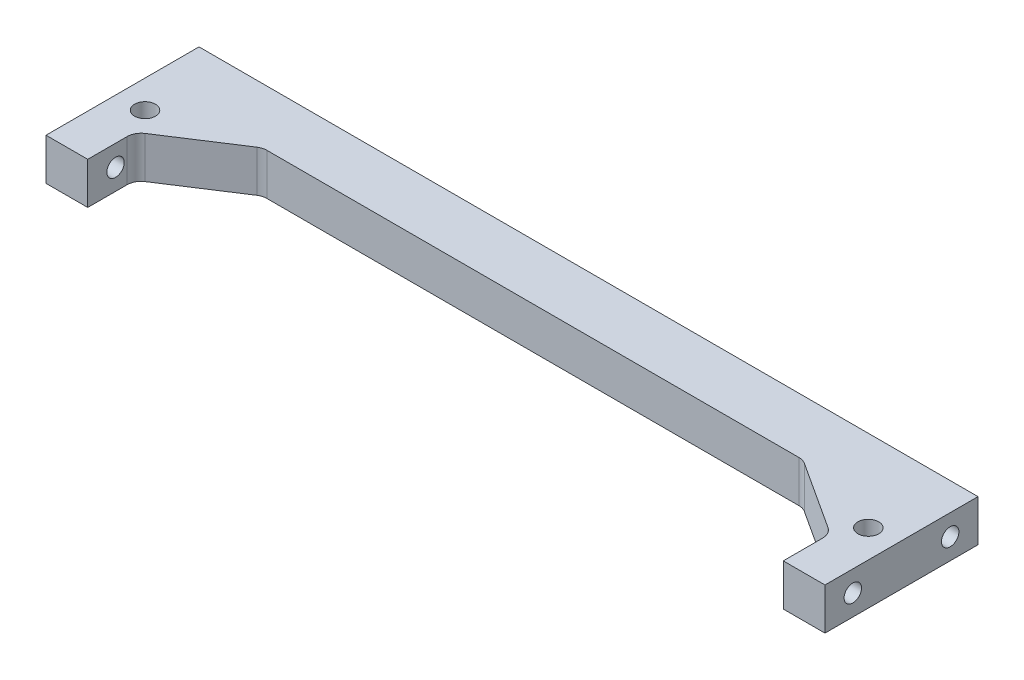
from build123d import *

# Parameters (mm, degrees)
SKETCH1_R                        = 1.5
BOSS_EXTRUDE1_DEPTH              = 6
FILLET1_R                        = 2
TAP_DRILL_FOR_M3_TAP1_AT_2_COUNT = 2
TAP_DRILL_FOR_M3_TAP1_AT_2_PITCH = 14
FILLET1_OF_MIRROR1_R             = 2


with BuildPart() as part:
    # Sketch1 → Boss-Extrude1 (new body)
    with BuildSketch(Plane(origin=(0, 0, 0), x_dir=(1, 0, 0), z_dir=(0, 1, 0))):
        Polygon((0, -22), (-56, -22), (-56, -44), (-50, -44), (-50, -37.239832831), (-38.851635079, -30), (0, -30), align=None)
        with Locations(Location((-51.997575213, -33.767620171, 0), (0, 0, 270))):
            Circle(SKETCH1_R, mode=Mode.SUBTRACT)
    boss_extrude1 = extrude(amount=BOSS_EXTRUDE1_DEPTH)

    # Fillet1
    fillet1_edges = [part.edges().sort_by_distance(p)[0] for p in [
        (-38.851635079, 3, 30),
        (-50, 3, 37.239832831),
    ]]
    fillet(fillet1_edges, radius=FILLET1_R)

    # Sketch2 → Tap Drill for M3 Tap1 (revolve, cut)
    with BuildSketch(Plane(origin=(-56, 3, 26), x_dir=(0, 0, 1), z_dir=(0, 1, 0))):
        Polygon((0, 0), (0, 10.751075774), (1.25, 10), (1.25, 0), align=None)
    tap_drill_for_m3_tap1 = revolve(axis=Axis((-62.35, 3, 26), (1, 0, 0)), mode=Mode.SUBTRACT)

    # Tap Drill for M3 Tap1 at 2: Tap Drill for M3 Tap1 ×2
    with Locations(*[(0, 0, i * TAP_DRILL_FOR_M3_TAP1_AT_2_PITCH) for i in range(1, TAP_DRILL_FOR_M3_TAP1_AT_2_COUNT)]):
        add(tap_drill_for_m3_tap1, mode=Mode.SUBTRACT)

    # Mirror1: Boss-Extrude1, Tap Drill for M3 Tap1 across plane
    add(boss_extrude1.mirror(Plane(origin=(0, 6, 30), x_dir=(0, 0, 1), z_dir=(-1, 0, 0))))
    add(tap_drill_for_m3_tap1.mirror(Plane(origin=(0, 6, 30), x_dir=(0, 0, 1), z_dir=(-1, 0, 0))), mode=Mode.SUBTRACT)

    # Mirror1 copy 1 sketch → Mirror1 copy 1 (revolve, cut)
    with BuildSketch(Plane(origin=(56, 3, 40), x_dir=(0, 0, 1), z_dir=(0, 1, 0))):
        Polygon((0, 0), (0, -10.751075774), (1.25, -10), (1.25, 0), align=None)
    revolve(axis=Axis((62.35, 3, 40), (1, 0, 0)), mode=Mode.SUBTRACT)

    # Fillet1 of Mirror1
    fillet1_of_mirror1_edges = [part.edges().sort_by_distance(p)[0] for p in [
        (38.851635079, 3, 30),
        (50, 3, 37.239832831),
    ]]
    fillet(fillet1_of_mirror1_edges, radius=FILLET1_OF_MIRROR1_R)


solid = part.part
